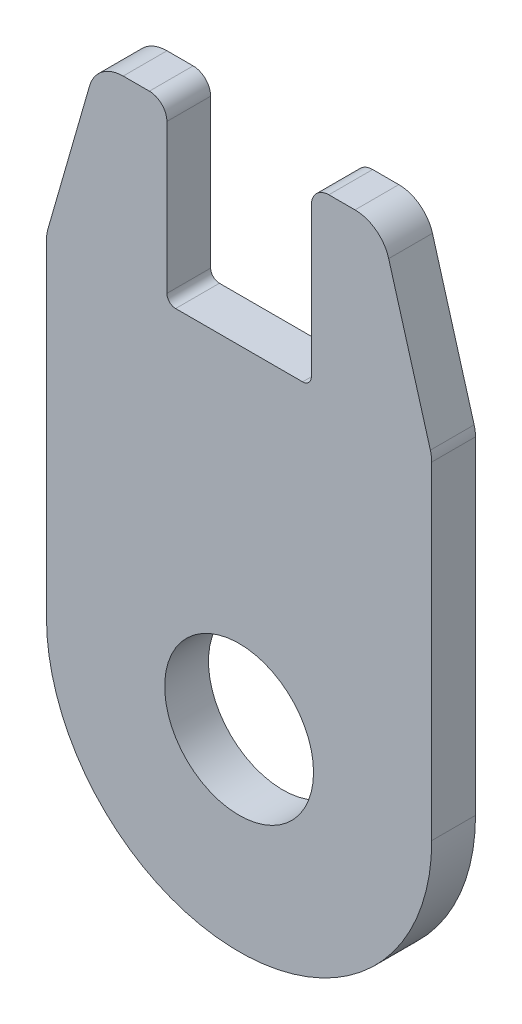
from build123d import *

# Parameters (mm, degrees)
SKETCH1_R      = 4.25
EXTRUDE1_DEPTH = 1.25


with BuildPart() as part:
    # Sketch1 → Extrude1 (new body, symmetric)
    with BuildSketch(Plane.XY):
        with BuildLine():
            Line((11, 0), (11, 18.718207384))
            ThreePointArc((11, 18.718207384), (10.980438994, 18.997243926), (10.922138608, 19.270822234))
            Line((10.922138608, 19.270822234), (8.541123231, 27.55261485))
            ThreePointArc((8.541123231, 27.55261485), (7.822057834, 28.597690474), (6.618984623, 29))
            Line((6.618984623, 29), (5.125, 29))
            ThreePointArc((5.125, 29), (4.417893219, 28.707106781), (4.125, 28))
            Line((4.125, 28), (4.125, 19.5))
            ThreePointArc((4.125, 19.5), (3.978553391, 19.146446609), (3.625, 19))
            Line((3.625, 19), (-3.625, 19))
            ThreePointArc((-3.625, 19), (-3.978553391, 19.146446609), (-4.125, 19.5))
            Line((-4.125, 19.5), (-4.125, 28))
            ThreePointArc((-4.125, 28), (-4.417893219, 28.707106781), (-5.125, 29))
            Line((-5.125, 29), (-6.618984623, 29))
            ThreePointArc((-6.618984623, 29), (-7.822057834, 28.597690474), (-8.541123231, 27.55261485))
            Line((-8.541123231, 27.55261485), (-10.922138608, 19.270822234))
            ThreePointArc((-10.922138608, 19.270822234), (-10.980438994, 18.997243926), (-11, 18.718207384))
            Line((-11, 18.718207384), (-11, 0))
            ThreePointArc((-11, 0), (0, -11), (11, 0))
        make_face()
        Circle(SKETCH1_R, mode=Mode.SUBTRACT)
    extrude(amount=EXTRUDE1_DEPTH, both=True)


solid = part.part
